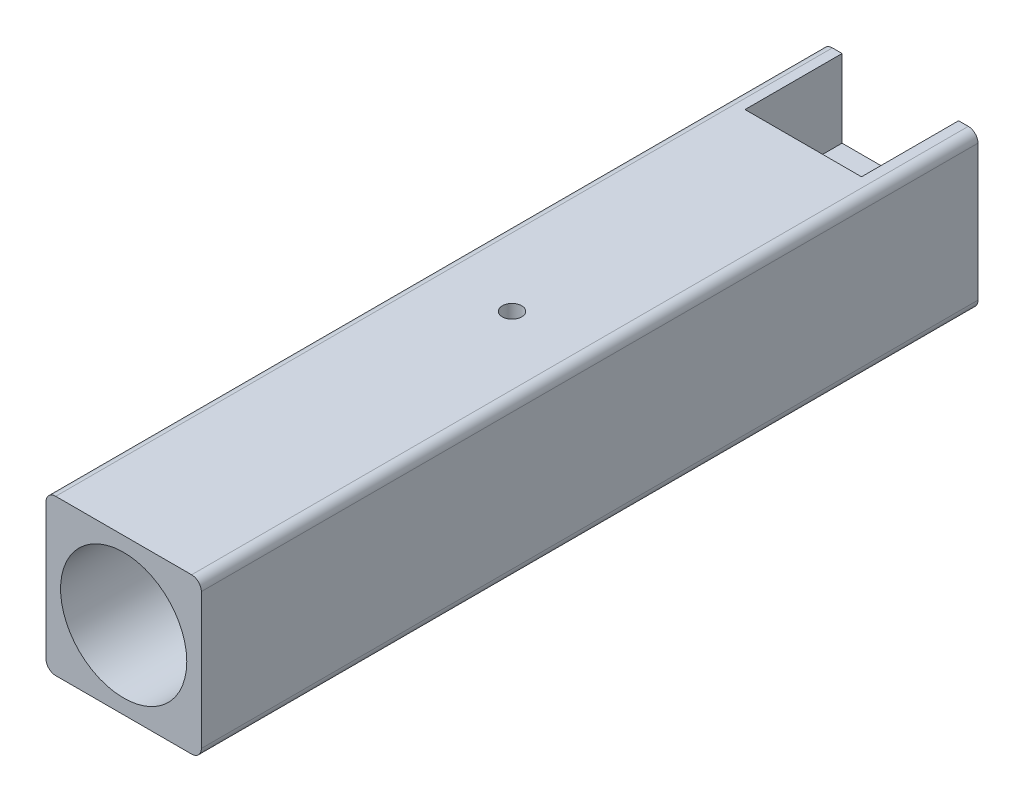
from build123d import *

# Parameters (mm, degrees)
SKETCH_1_W             = 16
SKETCH_1_H             = 16
EXTRUDE_1_DEPTH        = 80
SKETCH_2_R             = 6.5
CUT_EXTRUDE_1_DEPTH    = 50
SKETCH_10_W            = 12
SKETCH_10_H            = 8
SKETCH_10_H_2          = 3
CUT_EXTRUDE_2_DEPTH    = 10
SKETCH_11_R            = 3.25
CUT_EXTRUDE_5_DEPTH    = 1
HOLE_WIZARD_M4_1_D     = 3.3
HOLE_WIZARD_M4_1_DEPTH = 4
CUT_EXTRUDE_6_REACH    = 18
SKETCH_14_R            = 1
FILLET_1_R             = 1


with BuildPart() as part:
    # 草图1 → 凸台-拉伸1 (new body)
    with BuildSketch(Plane.XY):
        with Locations((8, -8)):
            Rectangle(SKETCH_1_W, SKETCH_1_H)
    extrude(amount=EXTRUDE_1_DEPTH)

    # 草图2 → 切除-拉伸1 (cut)
    with BuildSketch(Plane.XY.offset(80)):
        with Locations((8, -8)):
            Circle(SKETCH_2_R)
    extrude(amount=-CUT_EXTRUDE_1_DEPTH, mode=Mode.SUBTRACT)

    # 草图10 → 切除-拉伸2 (cut)
    with BuildSketch(Plane(origin=(0, 0, 0), x_dir=(-1, 0, 0), z_dir=(0, 0, -1))):
        with Locations((-8, -4)):
            Rectangle(SKETCH_10_W, SKETCH_10_H)
        with Locations((-8, -14.5)):
            Rectangle(SKETCH_10_W, SKETCH_10_H_2)
    extrude(amount=-CUT_EXTRUDE_2_DEPTH, mode=Mode.SUBTRACT)

    # 草图11 → 切除-拉伸5 (cut)
    with BuildSketch(Plane.XZ.offset(13)):
        with Locations((8, 5)):
            Circle(SKETCH_11_R)
    extrude(amount=-CUT_EXTRUDE_5_DEPTH, mode=Mode.SUBTRACT)

    # M4 螺纹孔的螺纹孔钻头1
    with Locations(Plane(origin=(0, -12, 0), x_dir=(-1, 0, 0), z_dir=(0, -1, 0))):
        with Locations((-8, -5)):
            Hole(HOLE_WIZARD_M4_1_D / 2, depth=HOLE_WIZARD_M4_1_DEPTH)

    # 草图14 → 切除-拉伸6 (cut, up to next)
    with BuildSketch(Plane(origin=(0, 0, 0), x_dir=(1, 0, 0), z_dir=(0, 1, 0)), mode=Mode.PRIVATE) as cut_extrude_6_sk1:
        with Locations((8, -40)):
            Circle(SKETCH_14_R)
    cut_extrude_6_tool1 = extrude(cut_extrude_6_sk1.sketch, amount=-CUT_EXTRUDE_6_REACH, mode=Mode.PRIVATE) & part.part
    add(cut_extrude_6_tool1.solids().sort_by_distance((8, 0, 40))[0], mode=Mode.SUBTRACT)

    # 圆角1
    fillet_1_edges = [part.edges().sort_by_distance(p)[0] for p in [
        (0, 0, 40),
        (16, 0, 40),
        (16, -16, 40),
        (0, -16, 40),
    ]]
    fillet(fillet_1_edges, radius=FILLET_1_R)


solid = part.part
